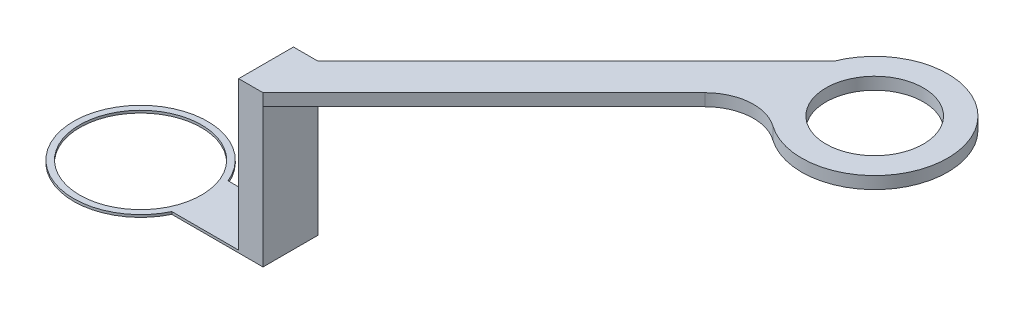
from build123d import *

# Parameters (mm, degrees)
CROQUIS1_R              = 5
SALIENTE_EXTRUIR2_DEPTH = 0.2
CROQUIS2_W              = 2
CROQUIS2_H              = 4.5
SALIENTE_EXTRUIR3_DEPTH = 12.2
CROQUIS7_W              = 4.5
CROQUIS7_H              = 1
SALIENTE_EXTRUIR6_DEPTH = 30
CROQUIS9_R              = 4
SALIENTE_EXTRUIR7_DEPTH = 1
REDONDEO1_R             = 4


with BuildPart() as part:
    # Croquis1 → Saliente-Extruir2 (new body)
    with BuildSketch(Plane(origin=(0, 0, 0), x_dir=(1, 0, 0), z_dir=(0, 1, 0))):
        with BuildLine():
            Line((5.078188303, 2.112345511), (12.443307855, 2.112345511))
            Line((12.443307855, 2.112345511), (12.443307855, -2.387654489))
            Line((12.443307855, -2.387654489), (4.954705444, -2.387654489))
            ThreePointArc((4.954705444, -2.387654489), (-5.49793045, 0.150866705), (5.078188303, 2.112345511))
        make_face()
        Circle(CROQUIS1_R, mode=Mode.SUBTRACT)
    extrude(amount=SALIENTE_EXTRUIR2_DEPTH)

    # Croquis2 → Saliente-Extruir3 (add)
    with BuildSketch(Plane(origin=(0, 0.2, 0), x_dir=(1, 0, 0), z_dir=(0, 1, 0))):
        with Locations((11.443307855, -0.137654489)):
            Rectangle(CROQUIS2_W, CROQUIS2_H)
    extrude(amount=SALIENTE_EXTRUIR3_DEPTH)

    # Croquis7 → Saliente-Extruir6 (add, along a direction that is not the sketch's normal)
    with BuildSketch(Plane(origin=(12.443307855, 0, 0), x_dir=(0, 0, -1), z_dir=(1, 0, 0))):
        with Locations((-0.137654489, 11.9)):
            Rectangle(CROQUIS7_W, CROQUIS7_H)
    extrude(amount=SALIENTE_EXTRUIR6_DEPTH, dir=(0.707106781, 0, -0.707106781))

    # Croquis9 → Saliente-Extruir7 (add)
    with BuildSketch(Plane(origin=(0, 12.4, 0), x_dir=(1, 0, 0), z_dir=(0, 1, 0))):
        with BuildLine():
            Line((33.656511291, 23.325548946), (33.656511291, 18.825548946))
            ThreePointArc((33.656511291, 18.825548946), (45.218660156, 21.075548946), (33.656511291, 23.325548946))
        make_face()
        with Locations((39.218660156, 21.075548946)):
            Circle(CROQUIS9_R, mode=Mode.SUBTRACT)
    extrude(amount=-SALIENTE_EXTRUIR7_DEPTH)

    # Redondeo1
    redondeo1_edges = [part.edges().sort_by_distance(p)[0] for p in [
        (33.656511291, 11.9, -18.825548946),
    ]]
    fillet(redondeo1_edges, radius=REDONDEO1_R)


solid = part.part
